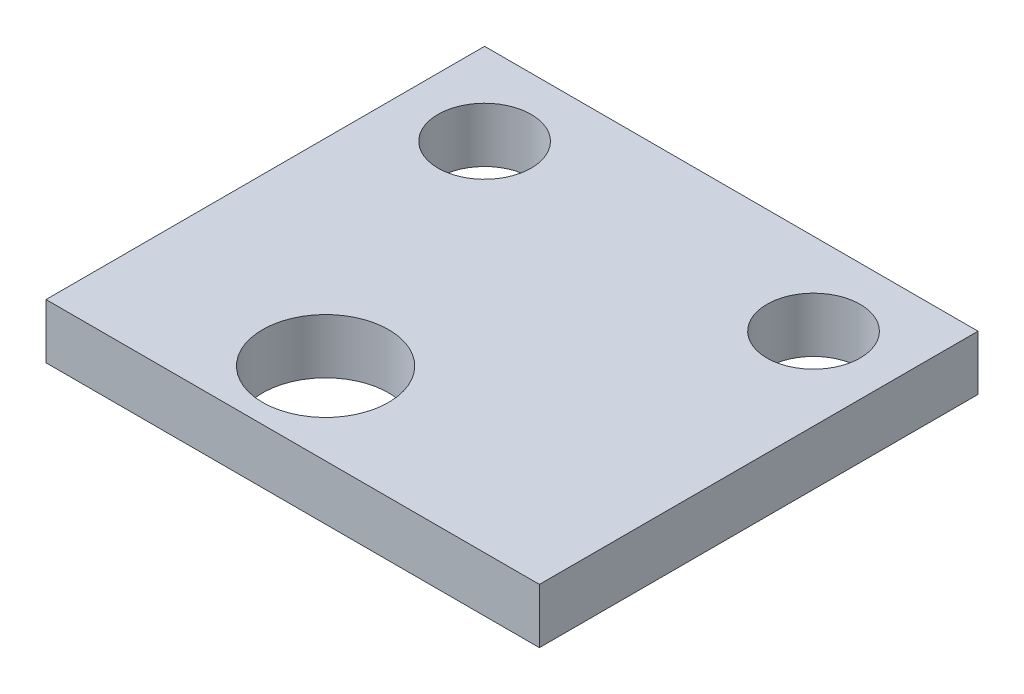
from build123d import *

# Parameters (mm, degrees)
SKETCH_1_W      = 9
SKETCH_1_H      = 8
SKETCH_1_R      = 0.85
SKETCH_1_R_2    = 1.15
EXTRUDE_1_DEPTH = 1


with BuildPart() as part:
    # Эскиз1 → Бобышка-Вытянуть1 (new body)
    with BuildSketch(Plane(origin=(0, 0, 0), x_dir=(1, 0, 0), z_dir=(0, 1, 0))):
        with Locations((4.5, 4)):
            Rectangle(SKETCH_1_W, SKETCH_1_H)
        with Locations((1.5, 6.5)):
            Circle(SKETCH_1_R, mode=Mode.SUBTRACT)
        with Locations((7.5, 6.5)):
            Circle(SKETCH_1_R, mode=Mode.SUBTRACT)
        with Locations((3.6, 1.5)):
            Circle(SKETCH_1_R_2, mode=Mode.SUBTRACT)
    extrude(amount=EXTRUDE_1_DEPTH)


solid = part.part
